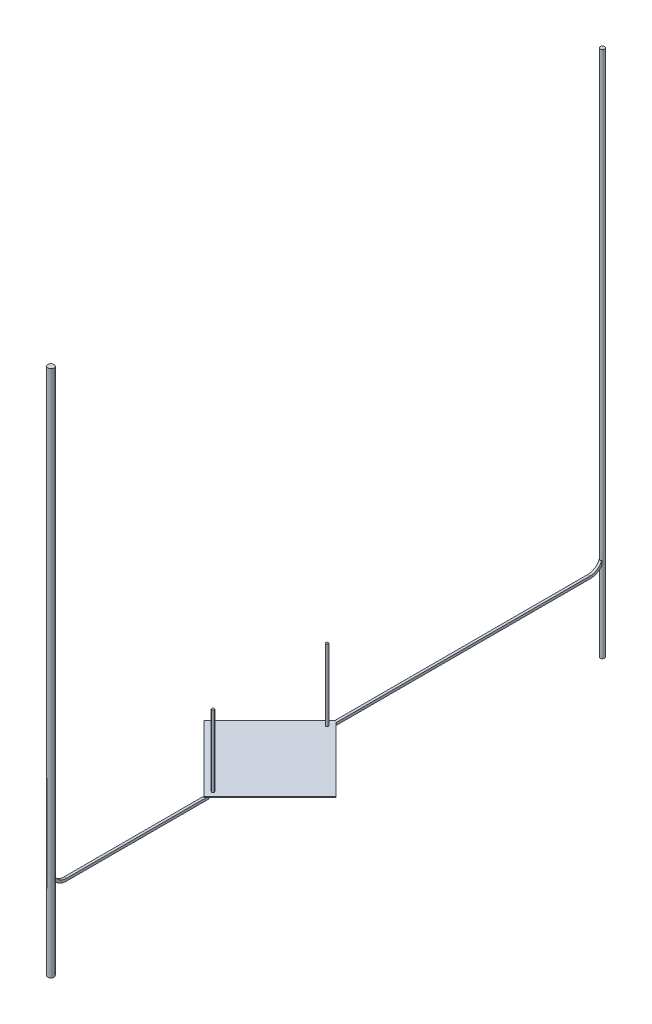
from build123d import *

# Parameters (mm, degrees)
SKETCH_1_W         = 15
SKETCH_1_H         = 15
EXTRUDE_1_DEPTH    = 0.1
SKETCH_2_R         = 0.2
EXTRUDE_2_DEPTH    = 11.5
EXTRUDE_2_2_DEPTH  = 11.5
EXTRUDE_3_DEPTH    = 0.05
SKETCH_3_W         = 0.8
SKETCH_3_H         = 2.5
EXTRUDE_3_2_DEPTH  = 0.05
EXTRUDE_3_3_DEPTH  = 0.05
SKETCH_4_W         = 4.2
SKETCH_4_H         = 2.5
EXTRUDE_4_DEPTH    = 0.05
SKETCH_5_R         = 0.1
EXTRUDE_5_DEPTH    = 0.3
EXTRUDE_6_DEPTH    = 0.05
SKETCH_7_W         = 1
SKETCH_7_H         = 1
EXTRUDE_7_DEPTH    = 0.3
MOVE_BODY_20_ANGLE = 45
SKETCH_27_R        = 0.35
EXTRUDE_30_DEPTH   = 72.5
SKETCH_28_R        = 0.5
EXTRUDE_31_DEPTH   = 72.5
SKETCH_29_W        = 42.2
SKETCH_29_H        = 0.4
EXTRUDE_32_DEPTH   = 0.2
SKETCH_33_W        = 23
SKETCH_33_H        = 0.4
EXTRUDE_34_DEPTH   = 0.2
SKETCH_40_W        = 0.4
SKETCH_40_H        = 0.4
REVOLVE_1_ANGLE    = 90
SKETCH_41_W        = 0.4
SKETCH_41_H        = 0.4
REVOLVE_2_ANGLE    = 90
SKETCH_43_R        = 0.35
EXTRUDE_35_DEPTH   = 12.5
SKETCH_44_R        = 0.5
EXTRUDE_36_DEPTH   = 12.5


with BuildPart() as part:
    # 草图1 → 凸台-拉伸1 (new body)
    with BuildSketch(Plane(origin=(0, 0, 0), x_dir=(1, 0, 0), z_dir=(0, 1, 0))):
        with Locations((7.5, 7.5)):
            Rectangle(SKETCH_1_W, SKETCH_1_H)
    extrude(amount=EXTRUDE_1_DEPTH)


with BuildPart() as body_2:
    # 草图2 → 凸台-拉伸2 (new body)
    with BuildSketch(Plane(origin=(0, 0.1, 0), x_dir=(1, 0, 0), z_dir=(0, 1, 0))):
        with Locations(Location((1, 1, 0), (0, 0, 270))):
            Circle(SKETCH_2_R)
    extrude(amount=EXTRUDE_2_DEPTH)


with BuildPart() as body_3:
    # 草图2 → Extrude 2 2 (new body)
    with BuildSketch(Plane(origin=(0, 0.1, 0), x_dir=(1, 0, 0), z_dir=(0, 1, 0))):
        with Locations(Location((14, 14, 0), (0, 0, 270))):
            Circle(SKETCH_2_R)
    extrude(amount=EXTRUDE_2_2_DEPTH)


with BuildPart() as body_4:
    # 草图3 → 凸台-拉伸3 (new body)
    with BuildSketch(Plane.XZ):
        Polygon((9.5, -14.5), (0.5, -14.5), (0.5, -0.5), (7.5, -0.5), (7.5, -9.5), (14.5, -9.5), (14.5, -14.5), align=None)
    extrude(amount=EXTRUDE_3_DEPTH)


with BuildPart() as body_5:
    # 草图3 → Extrude 3 2 (new body)
    with BuildSketch(Plane.XZ):
        with Locations((9.1, -1.75)):
            Rectangle(SKETCH_3_W, SKETCH_3_H)
    extrude(amount=EXTRUDE_3_2_DEPTH)

    # 草图5 → 凸台-拉伸5 (add)
    with BuildSketch(Plane.XZ.offset(0.05)):
        with Locations(Location((9.1, -0.9, 0), (0, 0, 270))):
            Circle(SKETCH_5_R)
    extrude(amount=EXTRUDE_5_DEPTH)


with BuildPart() as body_6:
    # 草图3 → Extrude 3 3 (new body)
    with BuildSketch(Plane.XZ):
        with Locations((14.1, -1.75)):
            Rectangle(SKETCH_3_W, SKETCH_3_H)
    extrude(amount=EXTRUDE_3_3_DEPTH)


with BuildPart() as body_7:
    # 草图4 → 凸台-拉伸4 (new body)
    with BuildSketch(Plane.XZ):
        with Locations((11.6, -1.75)):
            Rectangle(SKETCH_4_W, SKETCH_4_H)
    extrude(amount=EXTRUDE_4_DEPTH)


with BuildPart() as body_8:
    # 草图6 → 凸台-拉伸6 (new body)
    with BuildSketch(Plane.XZ.offset(0.35)):
        Polygon((9.1, -0.5), (0.5, -0.5), (0.5, -14.5), (9.5, -14.5), (9.5, -0.5), align=None)
    extrude(amount=EXTRUDE_6_DEPTH)


with BuildPart() as body_9:
    # 草图7 → 凸台-拉伸7 (new body)
    with BuildSketch(Plane.XZ.offset(0.05)):
        with Locations((13, -13)):
            Rectangle(SKETCH_7_W, SKETCH_7_H)
    extrude(amount=EXTRUDE_7_DEPTH)


with BuildPart() as body_6_1:
    # Move Body 19: moved
    add(body_6.part.moved(Location((-14, 0, 14))))


with BuildPart() as part_1:
    # Move Body 19: moved
    add(part.part.moved(Location((-14, 0, 14))))


with BuildPart() as body_9_1:
    # Move Body 19: moved
    add(body_9.part.moved(Location((-14, 0, 14))))


with BuildPart() as body_2_1:
    # Move Body 19: moved
    add(body_2.part.moved(Location((-14, 0, 14))))


with BuildPart() as body_8_1:
    # Move Body 19: moved
    add(body_8.part.moved(Location((-14, 0, 14))))


with BuildPart() as body_7_1:
    # Move Body 19: moved
    add(body_7.part.moved(Location((-14, 0, 14))))


with BuildPart() as body_5_1:
    # Move Body 19: moved
    add(body_5.part.moved(Location((-14, 0, 14))))


with BuildPart() as body_3_1:
    # Move Body 19: moved
    add(body_3.part.moved(Location((-14, 0, 14))))


with BuildPart() as body_4_1:
    # Move Body 19: moved
    add(body_4.part.moved(Location((-14, 0, 14))))


with BuildPart() as body_7_2:
    # Move Body 20: moved
    add(body_7_1.part.rotate(Axis((0, 0, 0), (0, 1, 0)), MOVE_BODY_20_ANGLE))


with BuildPart() as body_5_2:
    # Move Body 20: moved
    add(body_5_1.part.rotate(Axis((0, 0, 0), (0, 1, 0)), MOVE_BODY_20_ANGLE))


with BuildPart() as body_4_2:
    # Move Body 20: moved
    add(body_4_1.part.rotate(Axis((0, 0, 0), (0, 1, 0)), MOVE_BODY_20_ANGLE))


with BuildPart() as body_8_2:
    # Move Body 20: moved
    add(body_8_1.part.rotate(Axis((0, 0, 0), (0, 1, 0)), MOVE_BODY_20_ANGLE))


with BuildPart() as body_3_2:
    # Move Body 20: moved
    add(body_3_1.part.rotate(Axis((0, 0, 0), (0, 1, 0)), MOVE_BODY_20_ANGLE))


with BuildPart() as body_6_2:
    # Move Body 20: moved
    add(body_6_1.part.rotate(Axis((0, 0, 0), (0, 1, 0)), MOVE_BODY_20_ANGLE))


with BuildPart() as part_2:
    # Move Body 20: moved
    add(part_1.part.rotate(Axis((0, 0, 0), (0, 1, 0)), MOVE_BODY_20_ANGLE))


    add(body_4_2.part)  # 凸台-拉伸32 merges body 4
    # 草图29 → 凸台-拉伸32 (add, symmetric)
    with BuildSketch(Plane(origin=(0, 0, 0), x_dir=(0, 0, -1), z_dir=(1, 0, 0))):
        with Locations((21.1, -0.2)):
            Rectangle(SKETCH_29_W, SKETCH_29_H)
    extrude(amount=EXTRUDE_32_DEPTH, both=True)

    # 草图33 → 凸台-拉伸34 (add, symmetric)
    with BuildSketch(Plane(origin=(0, 0, 0), x_dir=(0, 0, -1), z_dir=(1, 0, 0))):
        with Locations((-30.695202125, -0.2)):
            Rectangle(SKETCH_33_W, SKETCH_33_H)
    extrude(amount=EXTRUDE_34_DEPTH, both=True)

    # 草图40 → 旋转1 (revolve)
    with BuildSketch(Plane(origin=(0, 0, -42.2), x_dir=(-1, 0, 0), z_dir=(0, 0, -1))):
        with Locations((0, -0.2)):
            Rectangle(SKETCH_40_W, SKETCH_40_H)
    revolve(axis=Axis((0.2, 2, -42.2), (1, 0, 0)), revolution_arc=REVOLVE_1_ANGLE)

    # 草图41 → 旋转2 (revolve)
    with BuildSketch(Plane.XY.offset(42.195202125)):
        with Locations((0, -0.2)):
            Rectangle(SKETCH_41_W, SKETCH_41_H)
    revolve(axis=Axis((-0.2, 2, 42.195202125), (-1, 0, 0)), revolution_arc=REVOLVE_2_ANGLE)


with BuildPart() as body_9_2:
    # Move Body 20: moved
    add(body_9_1.part.rotate(Axis((0, 0, 0), (0, 1, 0)), MOVE_BODY_20_ANGLE))


with BuildPart() as body_2_2:
    # Move Body 20: moved
    add(body_2_1.part.rotate(Axis((0, 0, 0), (0, 1, 0)), MOVE_BODY_20_ANGLE))


with BuildPart() as body_10:
    # 草图27 → 凸台-拉伸30 (new body)
    with BuildSketch(Plane(origin=(0, 0, 0), x_dir=(1, 0, 0), z_dir=(0, 1, 0))):
        with Locations(Location((0, 44.35, 0), (0, 0, 270))):
            Circle(SKETCH_27_R)
    extrude(amount=EXTRUDE_30_DEPTH)


    add(part_2.part)  # 凸台-拉伸35 merges part
    # 草图43 → 凸台-拉伸35 (add)
    with BuildSketch(Plane.XZ):
        with Locations(Location((0, -44.35, 0), (0, 0, 270))):
            Circle(SKETCH_43_R)
    extrude(amount=EXTRUDE_35_DEPTH)


with BuildPart() as body_11:
    # 草图28 → 凸台-拉伸31 (new body)
    with BuildSketch(Plane(origin=(0, 0, 0), x_dir=(1, 0, 0), z_dir=(0, 1, 0))):
        with Locations(Location((0, -44.5, 0), (0, 0, 270))):
            Circle(SKETCH_28_R)
    extrude(amount=EXTRUDE_31_DEPTH)


    add(body_10.part)  # 凸台-拉伸36 merges body 10
    # 草图44 → 凸台-拉伸36 (add)
    with BuildSketch(Plane.XZ):
        with Locations(Location((0, 44.5, 0), (0, 0, 270))):
            Circle(SKETCH_44_R)
    extrude(amount=EXTRUDE_36_DEPTH)


solid = Compound([body_7_2.part, body_5_2.part, body_8_2.part, body_3_2.part, body_6_2.part, body_9_2.part, body_2_2.part, body_11.part])
